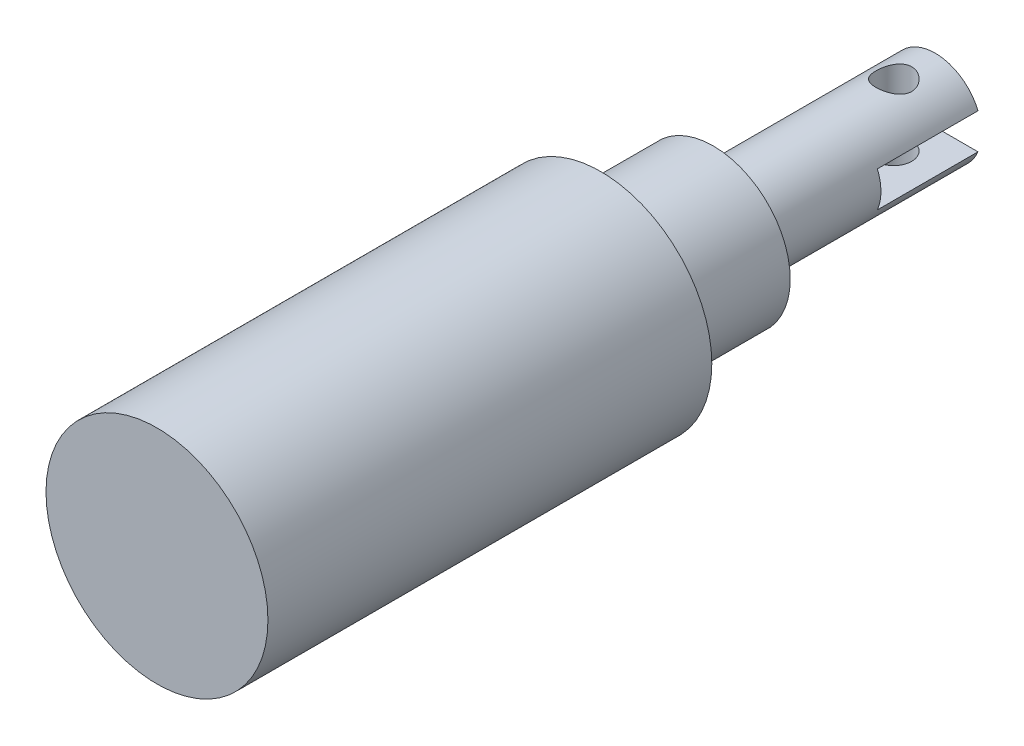
from build123d import *

# Parameters (mm, degrees)
SKETCH1_R               = 9.525
EXTRUDE1_DEPTH          = 38.1
SKETCH2_R               = 6.604
EXTRUDE2_DEPTH          = 9.652
SKETCH3_R               = 3.9751
EXTRUDE3_DEPTH          = 19.05
SKETCH4_W               = 10.16
SKETCH4_H               = 3.048
CUT_EXTRUDE1_DEPTH      = 8.636
SKETCH5_R               = 1.5367
CUT_EXTRUDE2_DEPTH      = 10.525
CUT_EXTRUDE2_DEPTH_BACK = 10.525


with BuildPart() as part:
    # Sketch1 → Extrude1 (new body)
    with BuildSketch(Plane.XY):
        Circle(SKETCH1_R)
    extrude(amount=EXTRUDE1_DEPTH)

    # Sketch2 → Extrude2 (add)
    with BuildSketch(Plane(origin=(0, 0, 0), x_dir=(-1, 0, 0), z_dir=(0, 0, -1))):
        Circle(SKETCH2_R)
    extrude(amount=EXTRUDE2_DEPTH)

    # Sketch3 → Extrude3 (add)
    with BuildSketch(Plane(origin=(0, 0, -9.652), x_dir=(-1, 0, 0), z_dir=(0, 0, -1))):
        Circle(SKETCH3_R)
    extrude(amount=EXTRUDE3_DEPTH)

    # Sketch4 → Cut-Extrude1 (cut)
    with BuildSketch(Plane(origin=(0, 0, -28.702), x_dir=(-1, 0, 0), z_dir=(0, 0, -1))):
        with Locations((0.063992248, 0)):
            Rectangle(SKETCH4_W, SKETCH4_H)
    extrude(amount=-CUT_EXTRUDE1_DEPTH, mode=Mode.SUBTRACT)

    # Sketch5 → Cut-Extrude2 (cut, two sides)
    with BuildSketch(Plane(origin=(0, 0, 0), x_dir=(1, 0, 0), z_dir=(0, 1, 0))) as cut_extrude2_sk:
        with Locations((0, 25.146)):
            Circle(SKETCH5_R)
    extrude(amount=CUT_EXTRUDE2_DEPTH, mode=Mode.SUBTRACT)
    extrude(cut_extrude2_sk.sketch, amount=-CUT_EXTRUDE2_DEPTH_BACK, mode=Mode.SUBTRACT)


solid = part.part
